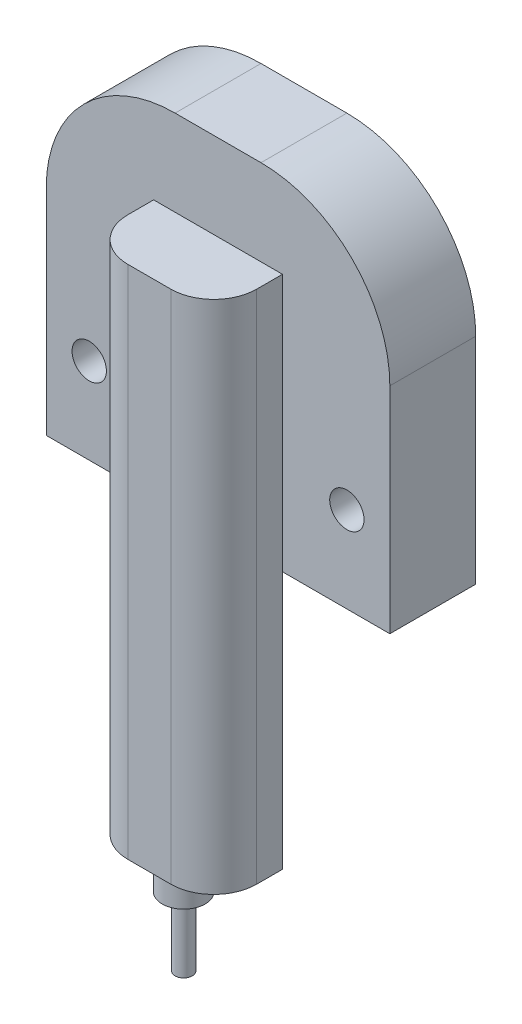
from build123d import *

# Parameters (mm, degrees)
SKETCH1_W           = 40
SKETCH1_H           = 10
BOSS_EXTRUDE1_DEPTH = 40
FILLET1_R           = 15
SKETCH3_R           = 2
CUT_EXTRUDE1_DEPTH  = 10
SKETCH7_W           = 15
SKETCH7_H           = 60
BOSS_EXTRUDE5_DEPTH = 8
SKETCH8_R           = 2.5
BOSS_EXTRUDE6_DEPTH = 4
SKETCH9_R           = 1
BOSS_EXTRUDE7_DEPTH = 8
FILLET3_R           = 5


with BuildPart() as part:
    # Sketch1 → Boss-Extrude1 (new body)
    with BuildSketch(Plane(origin=(0, 0, 0), x_dir=(1, 0, 0), z_dir=(0, 1, 0))):
        Rectangle(SKETCH1_W, SKETCH1_H)
    extrude(amount=BOSS_EXTRUDE1_DEPTH)

    # Fillet1
    fillet1_edges = [part.edges().sort_by_distance(p)[0] for p in [
        (-20, 40, 0),
        (20, 40, 0),
    ]]
    fillet(fillet1_edges, radius=FILLET1_R)

    # Sketch3 → Cut-Extrude1 (cut)
    with BuildSketch(Plane.XY.offset(5)):
        with Locations((15, 10)):
            Circle(SKETCH3_R)
        with Locations((-15, 10)):
            Circle(SKETCH3_R)
    extrude(amount=-CUT_EXTRUDE1_DEPTH, mode=Mode.SUBTRACT)

    # Sketch7 → Boss-Extrude5 (add)
    with BuildSketch(Plane.XY.offset(5)):
        Rectangle(SKETCH7_W, SKETCH7_H)
    extrude(amount=BOSS_EXTRUDE5_DEPTH)

    # Sketch8 → Boss-Extrude6 (add)
    with BuildSketch(Plane.XZ.offset(30)):
        with Locations((0, 9)):
            Circle(SKETCH8_R)
    extrude(amount=BOSS_EXTRUDE6_DEPTH)

    # Sketch9 → Boss-Extrude7 (add)
    with BuildSketch(Plane.XZ.offset(34)):
        with Locations((0, 9)):
            Circle(SKETCH9_R)
    extrude(amount=BOSS_EXTRUDE7_DEPTH)

    # Fillet3
    fillet3_edges = [part.edges().sort_by_distance(p)[0] for p in [
        (7.5, 0, 13),
        (-7.5, 0, 13),
    ]]
    fillet(fillet3_edges, radius=FILLET3_R)


solid = part.part
